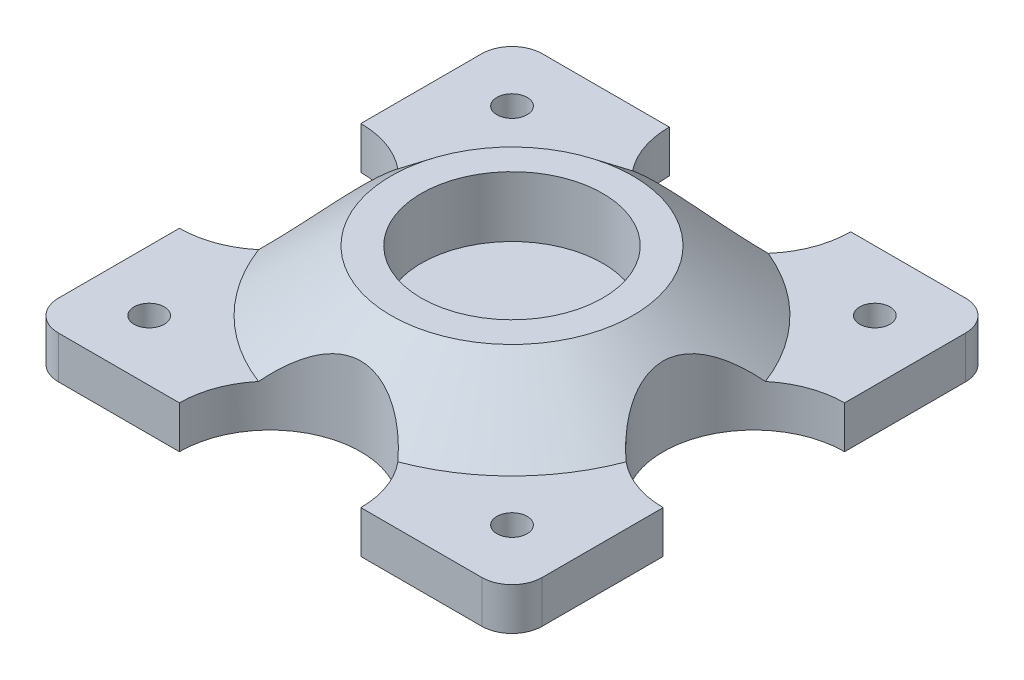
from build123d import *

# Parameters (mm, degrees)
BOSS_EXTRUDE2_DEPTH = 8.89
SKETCH11_R          = 19.05
CUT_EXTRUDE1_DEPTH  = 127
SKETCH12_R          = 19.05
CUT_EXTRUDE2_DEPTH  = 12.7
SKETCH13_R          = 3.175
CUT_EXTRUDE3_DEPTH  = 12.7


with BuildPart() as part:
    # Sketch1 → Boss-Extrude2 (new body)
    with BuildSketch(Plane(origin=(0, 0, 0), x_dir=(1, 0, 0), z_dir=(0, 1, 0))):
        with BuildLine():
            Line((-44.45, -50.8), (44.45, -50.8))
            ThreePointArc((44.45, -50.8), (48.940128061, -48.940128061), (50.8, -44.45))
            Line((50.8, -44.45), (50.8, 44.45))
            ThreePointArc((50.8, 44.45), (48.940128061, 48.940128061), (44.45, 50.8))
            Line((44.45, 50.8), (-44.45, 50.8))
            ThreePointArc((-44.45, 50.8), (-48.940128061, 48.940128061), (-50.8, 44.45))
            Line((-50.8, 44.45), (-50.8, -44.45))
            ThreePointArc((-50.8, -44.45), (-48.940128061, -48.940128061), (-44.45, -50.8))
        make_face()
    extrude(amount=BOSS_EXTRUDE2_DEPTH)

    # Sketch10 → Revolve1 (revolve)
    with BuildSketch(Plane.XY):
        Polygon((0, 21.59), (0, 8.89), (41.275, 8.89), (25.4, 21.59), align=None)
    revolve(axis=Axis((0, 0, 0), (0, 1, 0)))

    # Sketch11 → Cut-Extrude1 (cut)
    with BuildSketch(Plane(origin=(0, 21.59, 0), x_dir=(1, 0, 0), z_dir=(0, 1, 0))):
        with Locations((1.281459619, 50.8)):
            Circle(SKETCH11_R)
        with Locations((50.8, 0)):
            Circle(SKETCH11_R)
        with Locations((0, -50.8)):
            Circle(SKETCH11_R)
        with Locations((-50.8, 0)):
            Circle(SKETCH11_R)
    extrude(amount=-CUT_EXTRUDE1_DEPTH, mode=Mode.SUBTRACT)

    # Sketch12 → Cut-Extrude2 (cut)
    with BuildSketch(Plane(origin=(0, 21.59, 0), x_dir=(1, 0, 0), z_dir=(0, 1, 0))):
        Circle(SKETCH12_R)
    extrude(amount=-CUT_EXTRUDE2_DEPTH, mode=Mode.SUBTRACT)

    # Sketch13 → Cut-Extrude3 (cut)
    with BuildSketch(Plane(origin=(0, 8.89, 0), x_dir=(1, 0, 0), z_dir=(0, 1, 0))):
        with Locations((-38.1, 38.1)):
            Circle(SKETCH13_R)
        with Locations((38.1, 38.1)):
            Circle(SKETCH13_R)
        with Locations((38.1, -38.1)):
            Circle(SKETCH13_R)
        with Locations((-38.1, -38.1)):
            Circle(SKETCH13_R)
    extrude(amount=-CUT_EXTRUDE3_DEPTH, mode=Mode.SUBTRACT)


solid = part.part
